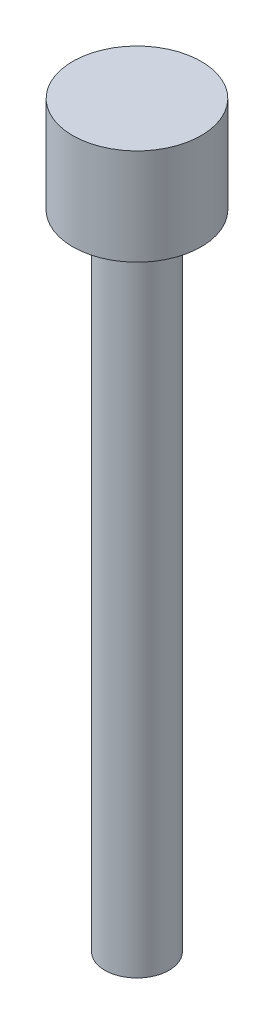
from build123d import *

# Parameters (mm, degrees)
SKETCH1_R           = 2.000000064
BOSS_EXTRUDE1_DEPTH = 3.000000096
SKETCH1_3_R         = 1.000000032
BOSS_EXTRUDE2_DEPTH = 19.999999878


with BuildPart() as part:
    # Sketch1 → Boss-Extrude1 (new body)
    with BuildSketch(Plane(origin=(0, 0, 0), x_dir=(1, 0, 0), z_dir=(0, 1, 0))):
        Circle(SKETCH1_R)
    extrude(amount=BOSS_EXTRUDE1_DEPTH)

    # Sketch1_3 → Boss-Extrude2 (add)
    with BuildSketch(Plane(origin=(0, 0, 0), x_dir=(1, 0, 0), z_dir=(0, 1, 0))):
        Circle(SKETCH1_3_R)
    extrude(amount=-BOSS_EXTRUDE2_DEPTH)


solid = part.part
